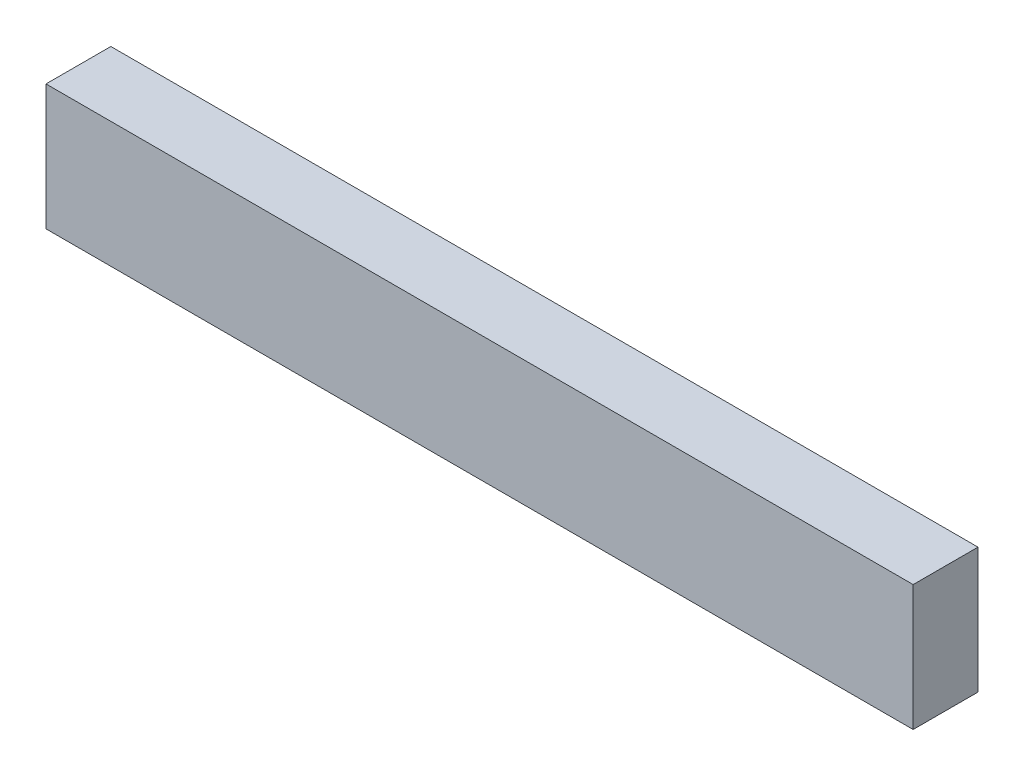
from build123d import *

# Parameters (mm, degrees)
SKETCH1_W           = 42.46
SKETCH1_H           = 6.1468
BOSS_EXTRUDE1_DEPTH = 3.175


with BuildPart() as part:
    # Sketch1 → Boss-Extrude1 (new body)
    with BuildSketch(Plane.XY):
        with Locations((0, 249.309595286)):
            Rectangle(SKETCH1_W, SKETCH1_H)
    extrude(amount=BOSS_EXTRUDE1_DEPTH)


solid = part.part
